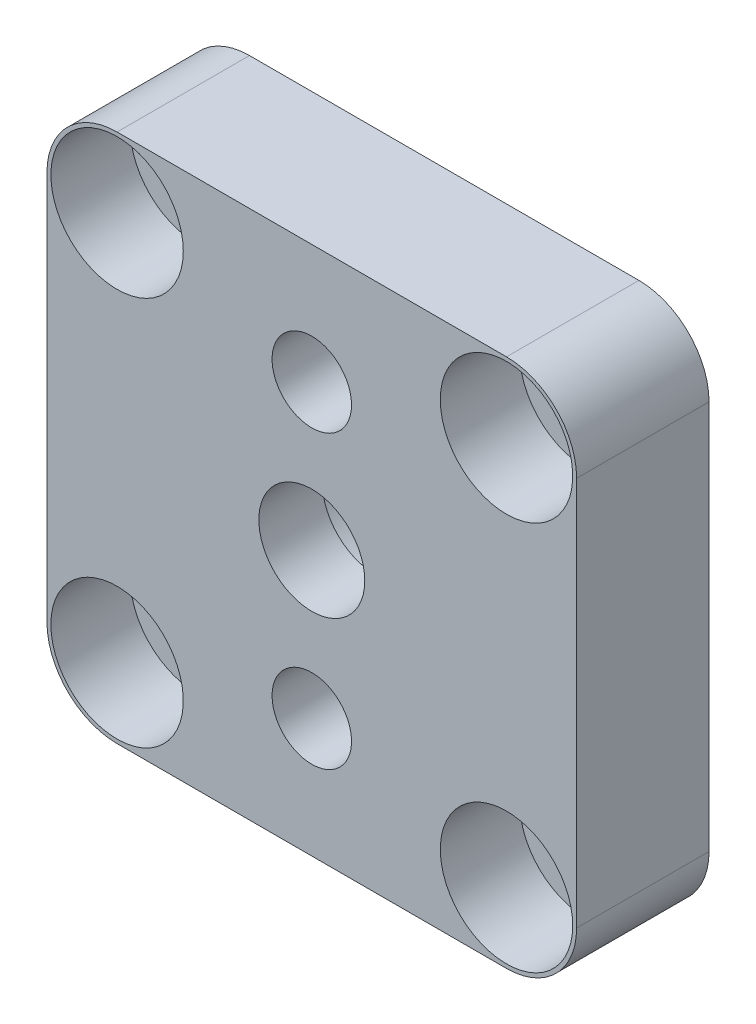
from build123d import *

# Parameters (mm, degrees)
SKIZZE3_W                       = 20
SKIZZE3_H                       = 20
SKIZZE3_R                       = 7.5
AUFSATZ_LINEAR_AUSTRAGEN2_DEPTH = 5
SKIZZE4_R                       = 1.05
SCHNITT_LINEAR_AUSTRAGEN1_DEPTH = 6
SKIZZE5_R                       = 1.5
SCHNITT_LINEAR_AUSTRAGEN2_DEPTH = 2.5
SCHNITT_LINEAR_AUSTRAGEN3_DEPTH = 6
SKIZZE7_R                       = 1.15
SCHNITT_LINEAR_AUSTRAGEN4_DEPTH = 6
SKIZZE8_R                       = 2.5
SCHNITT_LINEAR_AUSTRAGEN5_DEPTH = 3


with BuildPart() as part:
    # Skizze2 → Rotation1 (revolve)
    with BuildSketch(Plane(origin=(0, 0, 0), x_dir=(0, 0, -1), z_dir=(1, 0, 0))):
        Polygon((0, 3.75), (-1, 3.75), (-1, 3.25), (-2.6, 3.25), (-2.6, 2), (-5, 2), (-5, 7.5), (0, 7.5), align=None)
    revolve(axis=Axis((0, 0, 12.6), (0, 0, -1)))

    # Skizze3 → Aufsatz-Linear austragen2 (add, through all)
    with BuildSketch(Plane.XY.offset(5)):
        Rectangle(SKIZZE3_W, SKIZZE3_H)
        Circle(SKIZZE3_R, mode=Mode.SUBTRACT)
    extrude(amount=-AUFSATZ_LINEAR_AUSTRAGEN2_DEPTH)

    # Skizze4 → Schnitt-Linear austragen1 (cut, through all)
    with BuildSketch(Plane.XY.offset(5)):
        with Locations((0, 5.5)):
            Circle(SKIZZE4_R)
        with Locations((0, -5.5)):
            Circle(SKIZZE4_R)
    extrude(amount=-SCHNITT_LINEAR_AUSTRAGEN1_DEPTH, mode=Mode.SUBTRACT)

    # Skizze5 → Schnitt-Linear austragen2 (cut)
    with BuildSketch(Plane.XY.offset(5)):
        with Locations((0, 5.5)):
            Circle(SKIZZE5_R)
        with Locations((0, -5.5)):
            Circle(SKIZZE5_R)
    extrude(amount=-SCHNITT_LINEAR_AUSTRAGEN2_DEPTH, mode=Mode.SUBTRACT)

    # Skizze6 → Schnitt-Linear austragen3 (cut, through all)
    with BuildSketch(Plane.XY.offset(5)):
        with BuildLine():
            Line((-10, 7.352290732), (-10.887824638, 7.352290732))
            Line((-10.887824638, 7.352290732), (-10.887824638, 10.887824638))
            Line((-10.887824638, 10.887824638), (-7.352290732, 10.887824638))
            Line((-7.352290732, 10.887824638), (-7.352290732, 10))
            ThreePointArc((-7.352290732, 10), (-9.22450391, 9.22450391), (-10, 7.352290732))
        make_face()
        with BuildLine():
            Line((7.352290732, 10.887824638), (7.352290732, 10))
            ThreePointArc((7.352290732, 10), (9.22450391, 9.22450391), (10, 7.352290732))
            Line((10, 7.352290732), (10.887824638, 7.352290732))
            Line((10.887824638, 7.352290732), (10.887824638, 10.887824638))
            Line((10.887824638, 10.887824638), (7.352290732, 10.887824638))
        make_face()
        with BuildLine():
            Line((10, -7.352290732), (10.887824638, -7.352290732))
            Line((10.887824638, -7.352290732), (10.887824638, -10.887824638))
            Line((10.887824638, -10.887824638), (7.352290732, -10.887824638))
            Line((7.352290732, -10.887824638), (7.352290732, -10))
            ThreePointArc((7.352290732, -10), (9.22450391, -9.22450391), (10, -7.352290732))
        make_face()
        with BuildLine():
            Line((-7.352290732, -10.887824638), (-7.352290732, -10))
            ThreePointArc((-7.352290732, -10), (-9.22450391, -9.22450391), (-10, -7.352290732))
            Line((-10, -7.352290732), (-10.887824638, -7.352290732))
            Line((-10.887824638, -7.352290732), (-10.887824638, -10.887824638))
            Line((-10.887824638, -10.887824638), (-7.352290732, -10.887824638))
        make_face()
    extrude(amount=-SCHNITT_LINEAR_AUSTRAGEN3_DEPTH, mode=Mode.SUBTRACT)

    # Skizze7 → Schnitt-Linear austragen4 (cut, through all)
    with BuildSketch(Plane.XY.offset(5)):
        with Locations((-7.352290732, 7.352290732)):
            Circle(SKIZZE7_R)
        with Locations((7.352290732, 7.352290732)):
            Circle(SKIZZE7_R)
        with Locations((7.352290732, -7.352290732)):
            Circle(SKIZZE7_R)
        with Locations((-7.352290732, -7.352290732)):
            Circle(SKIZZE7_R)
    extrude(amount=-SCHNITT_LINEAR_AUSTRAGEN4_DEPTH, mode=Mode.SUBTRACT)

    # Skizze8 → Schnitt-Linear austragen5 (cut)
    with BuildSketch(Plane.XY.offset(5)):
        with Locations((-7.352290732, 7.352290732)):
            Circle(SKIZZE8_R)
        with Locations((7.352290732, 7.352290732)):
            Circle(SKIZZE8_R)
        with Locations((7.352290732, -7.352290732)):
            Circle(SKIZZE8_R)
        with Locations((-7.352290732, -7.352290732)):
            Circle(SKIZZE8_R)
    extrude(amount=-SCHNITT_LINEAR_AUSTRAGEN5_DEPTH, mode=Mode.SUBTRACT)


solid = part.part
